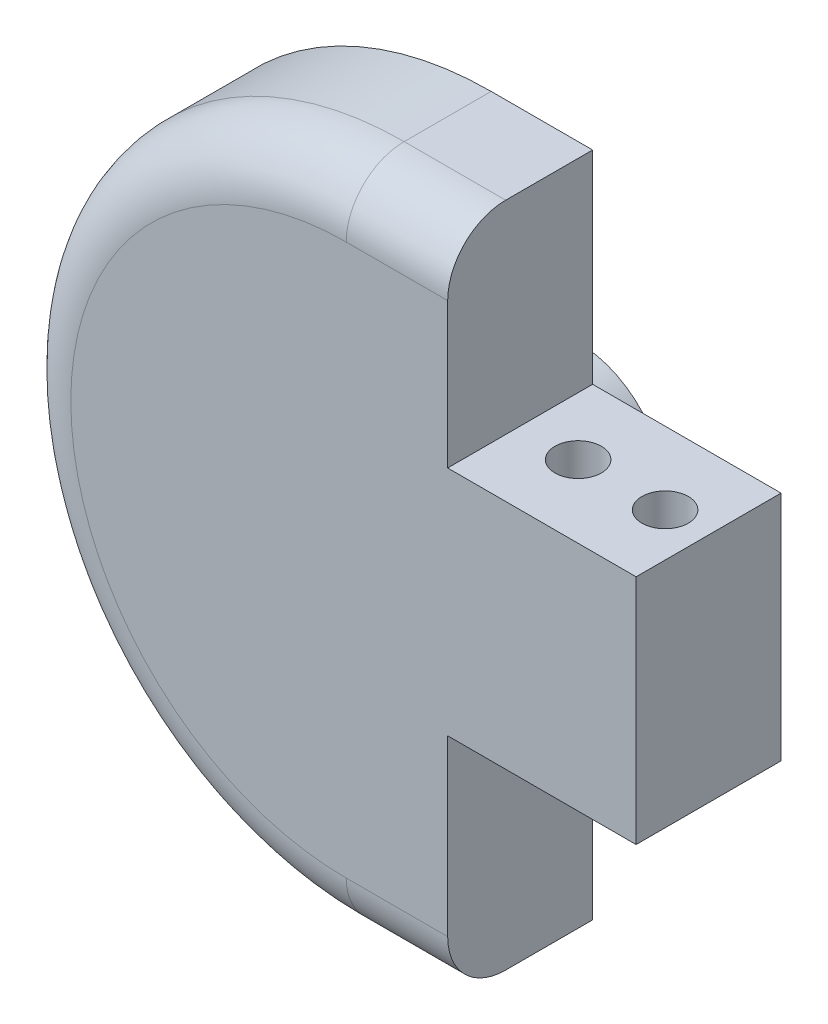
from build123d import *

# Parameters (mm, degrees)
BOSS_EXTRUDE1_DEPTH = 5
CUT_EXTRUDE1_START  = 11
SKETCH2_R           = 0.8
CUT_EXTRUDE1_DEPTH  = 23
SKETCH4_R           = 3
BOSS_EXTRUDE2_DEPTH = 3
FILLET1_R           = 2


with BuildPart() as part:
    # Sketch1 → Boss-Extrude1 (new body)
    with BuildSketch(Plane.XY):
        with BuildLine():
            Line((3.5, 12), (3.5, 5))
            Line((3.5, 5), (10, 5))
            Line((10, 5), (10, -3))
            Line((10, -3), (3.5, -3))
            Line((3.5, -3), (3.5, -11))
            Line((3.5, -11), (0, -11))
            ThreePointArc((0, -11), (-11.5, 0.5), (0, 12))
            Line((0, 12), (3.5, 12))
        make_face()
    extrude(amount=BOSS_EXTRUDE1_DEPTH)

    # Sketch2 → Cut-Extrude1 (cut, through all)
    with BuildSketch(Plane(origin=(0, 0, 0), x_dir=(1, 0, 0), z_dir=(0, 1, 0)).offset(CUT_EXTRUDE1_START)):
        with Locations((8.5, -2.5)):
            Circle(SKETCH2_R)
        with Locations((5.5, -2.5)):
            Circle(SKETCH2_R)
    extrude(amount=-CUT_EXTRUDE1_DEPTH, mode=Mode.SUBTRACT)

    # Sketch4 → Boss-Extrude2 (add)
    with BuildSketch(Plane.XY):
        Circle(SKETCH4_R)
    extrude(amount=-BOSS_EXTRUDE2_DEPTH)

    # Fillet1
    fillet1_edges = [part.edges().sort_by_distance(p)[0] for p in [
        (1.75, 12, 5),
        (-11.5, 0.5, 5),
        (1.75, -11, 5),
    ]]
    fillet(fillet1_edges, radius=FILLET1_R)


solid = part.part
